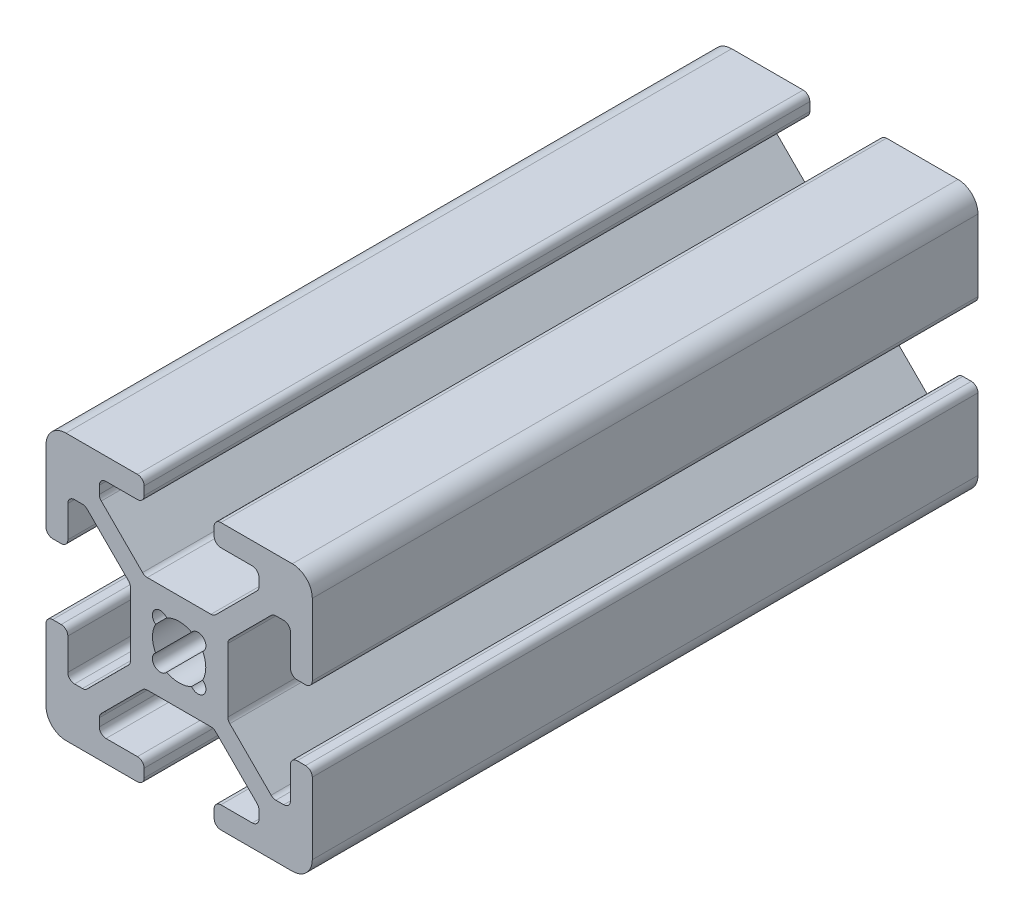
from build123d import *

# Parameters (mm, degrees)
BOSS_EXTRUDE1_DEPTH = 50


with BuildPart() as part:
    # Sketch1 → Boss-Extrude1 (new body)
    with BuildSketch(Plane.XY):
        with BuildLine():
            Line((-2.746356642, -3.807016814), (-5.847983186, -6.908643358))
            ThreePointArc((-5.847983186, -6.908643358), (-5.956791575, -7.07148662), (-5.995, -7.263573344))
            Line((-5.995, -7.263573344), (-5.995, -7.858053199))
            ThreePointArc((-5.995, -7.858053199), (-5.847983186, -8.212983186), (-5.493053199, -8.36))
            Line((-5.493053199, -8.36), (-3.131946801, -8.36))
            ThreePointArc((-3.131946801, -8.36), (-2.777016814, -8.507016814), (-2.63, -8.861946801))
            Line((-2.63, -8.861946801), (-2.63, -9.498053199))
            ThreePointArc((-2.63, -9.498053199), (-2.777016814, -9.852983186), (-3.131946801, -10))
            Line((-3.131946801, -10), (-8.5, -10))
            ThreePointArc((-8.5, -10), (-9.560660172, -9.560660172), (-10, -8.5))
            Line((-10, -8.5), (-10, -3.131946801))
            ThreePointArc((-10, -3.131946801), (-9.852983186, -2.777016814), (-9.498053199, -2.63))
            Line((-9.498053199, -2.63), (-8.861946801, -2.63))
            ThreePointArc((-8.861946801, -2.63), (-8.507016814, -2.777016814), (-8.36, -3.131946801))
            Line((-8.36, -3.131946801), (-8.36, -5.493053199))
            ThreePointArc((-8.36, -5.493053199), (-8.212983186, -5.847983186), (-7.858053199, -5.995))
            Line((-7.858053199, -5.995), (-7.263573344, -5.995))
            ThreePointArc((-7.263573344, -5.995), (-7.07148662, -5.956791575), (-6.908643358, -5.847983186))
            Line((-6.908643358, -5.847983186), (-3.807016814, -2.746356642))
            ThreePointArc((-3.807016814, -2.746356642), (-3.698208425, -2.58351338), (-3.66, -2.391426656))
            Line((-3.66, -2.391426656), (-3.66, 2.391426656))
            ThreePointArc((-3.66, 2.391426656), (-3.698208425, 2.58351338), (-3.807016814, 2.746356642))
            Line((-3.807016814, 2.746356642), (-6.908643358, 5.847983186))
            ThreePointArc((-6.908643358, 5.847983186), (-7.07148662, 5.956791575), (-7.263573344, 5.995))
            Line((-7.263573344, 5.995), (-7.858053199, 5.995))
            ThreePointArc((-7.858053199, 5.995), (-8.212983186, 5.847983186), (-8.36, 5.493053199))
            Line((-8.36, 5.493053199), (-8.36, 3.131946801))
            ThreePointArc((-8.36, 3.131946801), (-8.507016814, 2.777016814), (-8.861946801, 2.63))
            Line((-8.861946801, 2.63), (-9.498053199, 2.63))
            ThreePointArc((-9.498053199, 2.63), (-9.852983186, 2.777016814), (-10, 3.131946801))
            Line((-10, 3.131946801), (-10, 8.5))
            ThreePointArc((-10, 8.5), (-9.560660172, 9.560660172), (-8.5, 10))
            Line((-8.5, 10), (-3.131946801, 10))
            ThreePointArc((-3.131946801, 10), (-2.777016814, 9.852983186), (-2.63, 9.498053199))
            Line((-2.63, 9.498053199), (-2.63, 8.861946801))
            ThreePointArc((-2.63, 8.861946801), (-2.777016814, 8.507016814), (-3.131946801, 8.36))
            Line((-3.131946801, 8.36), (-5.493053199, 8.36))
            ThreePointArc((-5.493053199, 8.36), (-5.847983186, 8.212983186), (-5.995, 7.858053199))
            Line((-5.995, 7.858053199), (-5.995, 7.263573344))
            ThreePointArc((-5.995, 7.263573344), (-5.956791575, 7.07148662), (-5.847983186, 6.908643358))
            Line((-5.847983186, 6.908643358), (-2.746356642, 3.807016814))
            ThreePointArc((-2.746356642, 3.807016814), (-2.58351338, 3.698208425), (-2.391426656, 3.66))
            Line((-2.391426656, 3.66), (2.391426656, 3.66))
            ThreePointArc((2.391426656, 3.66), (2.58351338, 3.698208425), (2.746356642, 3.807016814))
            Line((2.746356642, 3.807016814), (5.847983186, 6.908643358))
            ThreePointArc((5.847983186, 6.908643358), (5.956791575, 7.07148662), (5.995, 7.263573344))
            Line((5.995, 7.263573344), (5.995, 7.858053199))
            ThreePointArc((5.995, 7.858053199), (5.847983186, 8.212983186), (5.493053199, 8.36))
            Line((5.493053199, 8.36), (3.131946801, 8.36))
            ThreePointArc((3.131946801, 8.36), (2.777016814, 8.507016814), (2.63, 8.861946801))
            Line((2.63, 8.861946801), (2.63, 9.498053199))
            ThreePointArc((2.63, 9.498053199), (2.777016814, 9.852983186), (3.131946801, 10))
            Line((3.131946801, 10), (8.5, 10))
            ThreePointArc((8.5, 10), (9.560660172, 9.560660172), (10, 8.5))
            Line((10, 8.5), (10, 3.131946801))
            ThreePointArc((10, 3.131946801), (9.852983186, 2.777016814), (9.498053199, 2.63))
            Line((9.498053199, 2.63), (8.861946801, 2.63))
            ThreePointArc((8.861946801, 2.63), (8.507016814, 2.777016814), (8.36, 3.131946801))
            Line((8.36, 3.131946801), (8.36, 5.493053199))
            ThreePointArc((8.36, 5.493053199), (8.212983186, 5.847983186), (7.858053199, 5.995))
            Line((7.858053199, 5.995), (7.263573344, 5.995))
            ThreePointArc((7.263573344, 5.995), (7.07148662, 5.956791575), (6.908643358, 5.847983186))
            Line((6.908643358, 5.847983186), (3.807016814, 2.746356642))
            ThreePointArc((3.807016814, 2.746356642), (3.698208425, 2.58351338), (3.66, 2.391426656))
            Line((3.66, 2.391426656), (3.66, -2.391426656))
            ThreePointArc((3.66, -2.391426656), (3.698208425, -2.58351338), (3.807016814, -2.746356642))
            Line((3.807016814, -2.746356642), (6.908643358, -5.847983186))
            ThreePointArc((6.908643358, -5.847983186), (7.07148662, -5.956791575), (7.263573344, -5.995))
            Line((7.263573344, -5.995), (7.858053199, -5.995))
            ThreePointArc((7.858053199, -5.995), (8.212983186, -5.847983186), (8.36, -5.493053199))
            Line((8.36, -5.493053199), (8.36, -3.131946801))
            ThreePointArc((8.36, -3.131946801), (8.507016814, -2.777016814), (8.861946801, -2.63))
            Line((8.861946801, -2.63), (9.498053199, -2.63))
            ThreePointArc((9.498053199, -2.63), (9.852983186, -2.777016814), (10, -3.131946801))
            Line((10, -3.131946801), (10, -8.5))
            ThreePointArc((10, -8.5), (9.560660172, -9.560660172), (8.5, -10))
            Line((8.5, -10), (3.131946801, -10))
            ThreePointArc((3.131946801, -10), (2.777016814, -9.852983186), (2.63, -9.498053199))
            Line((2.63, -9.498053199), (2.63, -8.861946801))
            ThreePointArc((2.63, -8.861946801), (2.777016814, -8.507016814), (3.131946801, -8.36))
            Line((3.131946801, -8.36), (5.493053199, -8.36))
            ThreePointArc((5.493053199, -8.36), (5.847983186, -8.212983186), (5.995, -7.858053199))
            Line((5.995, -7.858053199), (5.995, -7.263573344))
            ThreePointArc((5.995, -7.263573344), (5.956791575, -7.07148662), (5.847983186, -6.908643358))
            Line((5.847983186, -6.908643358), (2.746356642, -3.807016814))
            ThreePointArc((2.746356642, -3.807016814), (2.58351338, -3.698208425), (2.391426656, -3.66))
            Line((2.391426656, -3.66), (-2.391426656, -3.66))
            ThreePointArc((-2.391426656, -3.66), (-2.58351338, -3.698208425), (-2.746356642, -3.807016814))
        make_face()
        with BuildLine():
            ThreePointArc((-1.767678053, 0.935582333), (-2, 0), (-1.767678053, -0.935582333))
            ThreePointArc((-1.767678053, -0.935582333), (-1.834942097, -1.834942097), (-0.935582333, -1.767678053))
            ThreePointArc((-0.935582333, -1.767678053), (0, -2), (0.935582333, -1.767678053))
            ThreePointArc((0.935582333, -1.767678053), (1.834942097, -1.834942097), (1.767678053, -0.935582333))
            ThreePointArc((1.767678053, -0.935582333), (2, 0), (1.767678053, 0.935582333))
            ThreePointArc((1.767678053, 0.935582333), (1.834942097, 1.834942097), (0.935582333, 1.767678053))
            ThreePointArc((0.935582333, 1.767678053), (0, 2), (-0.935582333, 1.767678053))
            ThreePointArc((-0.935582333, 1.767678053), (-1.834942097, 1.834942097), (-1.767678053, 0.935582333))
        make_face(mode=Mode.SUBTRACT)
    extrude(amount=BOSS_EXTRUDE1_DEPTH)


solid = part.part
